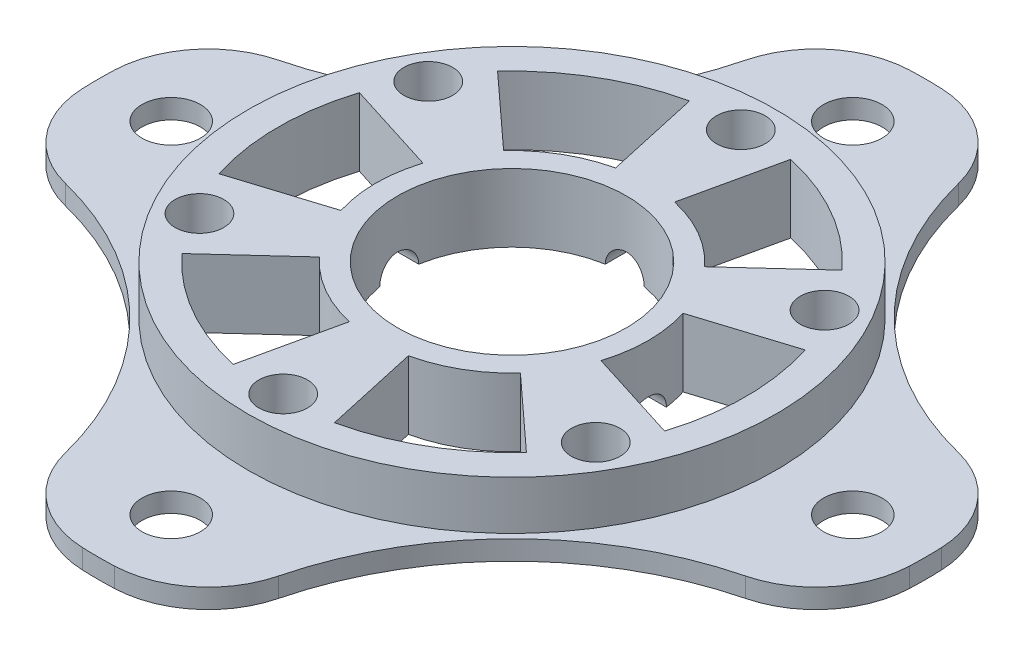
from build123d import *

# Parameters (mm, degrees)
SKETCH1_R           = 27.1
BOSS_EXTRUDE1_DEPTH = 5
SKETCH2_R           = 42.5
BOSS_EXTRUDE2_DEPTH = 2
SKETCH3_R           = 3
CUT_EXTRUDE1_DEPTH  = 2
SKETCH4_R           = 11.75
SKETCH4_R_2         = 2.5
CUT_EXTRUDE2_DEPTH  = 8
CUT_EXTRUDE3_DEPTH  = 8
FILLET1_R           = 10
SKETCH7_R           = 2
CUT_EXTRUDE4_DEPTH  = 15
SKETCH8_R           = 2
CUT_EXTRUDE5_DEPTH  = 25


with BuildPart() as part:
    # Sketch1 → Boss-Extrude1 (new body)
    with BuildSketch(Plane(origin=(0, 0, 0), x_dir=(1, 0, 0), z_dir=(0, 1, 0))):
        Circle(SKETCH1_R)
    extrude(amount=-BOSS_EXTRUDE1_DEPTH)

    # Sketch2 → Boss-Extrude2 (add)
    with BuildSketch(Plane.XZ.offset(5)):
        Circle(SKETCH2_R)
    extrude(amount=BOSS_EXTRUDE2_DEPTH)

    # Sketch3 → Cut-Extrude1 (cut)
    with BuildSketch(Plane(origin=(0, -5, 0), x_dir=(1, 0, 0), z_dir=(0, 1, 0))):
        with BuildLine():
            ThreePointArc((-41.306779105, 10), (-19.624107624, 19.624107624), (-10, 41.306779105))
            ThreePointArc((-10, 41.306779105), (-30.0520382, 30.0520382), (-41.306779105, 10))
        make_face()
        with Locations((0, 35)):
            Circle(SKETCH3_R)
        with BuildLine():
            ThreePointArc((41.306779105, 10), (30.0520382, 30.0520382), (10, 41.306779105))
            ThreePointArc((10, 41.306779105), (19.624107624, 19.624107624), (41.306779105, 10))
        make_face()
        with Locations((35, 0)):
            Circle(SKETCH3_R)
        with Locations((0, -35)):
            Circle(SKETCH3_R)
        with BuildLine():
            ThreePointArc((41.306779105, -10), (19.624107624, -19.624107624), (10, -41.306779105))
            ThreePointArc((10, -41.306779105), (30.0520382, -30.0520382), (41.306779105, -10))
        make_face()
        with BuildLine():
            ThreePointArc((-10, -41.306779105), (-19.624107624, -19.624107624), (-41.306779105, -10))
            ThreePointArc((-41.306779105, -10), (-30.0520382, -30.0520382), (-10, -41.306779105))
        make_face()
        with Locations((-35, 0)):
            Circle(SKETCH3_R)
    extrude(amount=-CUT_EXTRUDE1_DEPTH, mode=Mode.SUBTRACT)

    # Sketch4 → Cut-Extrude2 (cut, through all)
    with BuildSketch(Plane(origin=(0, 0, 0), x_dir=(1, 0, 0), z_dir=(0, 1, 0))):
        Circle(SKETCH4_R)
        with Locations((0, 23.5)):
            Circle(SKETCH4_R_2)
        with Locations((20.351596989, 11.75)):
            Circle(SKETCH4_R_2)
        with Locations((20.351596989, -11.75)):
            Circle(SKETCH4_R_2)
        with Locations((0, -23.5)):
            Circle(SKETCH4_R_2)
        with Locations((-20.351596989, -11.75)):
            Circle(SKETCH4_R_2)
        with Locations((-20.351596989, 11.75)):
            Circle(SKETCH4_R_2)
    extrude(amount=-CUT_EXTRUDE2_DEPTH, mode=Mode.SUBTRACT)

    # Sketch5 → Cut-Extrude3 (cut, through all)
    with BuildSketch(Plane(origin=(0, 0, 0), x_dir=(1, 0, 0), z_dir=(0, 1, 0))):
        with BuildLine():
            Line((-17.694656083, 16.214164983), (-10.321882715, 9.458262907))
            ThreePointArc((-10.321882715, 9.458262907), (-7, 12.124355653), (-3.030154595, 13.6681441))
            Line((-3.030154595, 13.6681441), (-5.194550735, 23.431104171))
            ThreePointArc((-5.194550735, 23.431104171), (-12, 20.784609691), (-17.694656083, 16.214164983))
        make_face()
        with BuildLine():
            Line((17.694656083, 16.214164983), (10.321882715, 9.458262907))
            ThreePointArc((10.321882715, 9.458262907), (7, 12.124355653), (3.030154595, 13.6681441))
            Line((3.030154595, 13.6681441), (5.194550735, 23.431104171))
            ThreePointArc((5.194550735, 23.431104171), (12, 20.784609691), (17.694656083, 16.214164983))
        make_face()
        with BuildLine():
            Line((22.889206818, -7.216939188), (13.35203731, -4.209881193))
            ThreePointArc((13.35203731, -4.209881193), (14, 0), (13.35203731, 4.209881193))
            Line((13.35203731, 4.209881193), (22.889206818, 7.216939188))
            ThreePointArc((22.889206818, 7.216939188), (24, 0), (22.889206818, -7.216939188))
        make_face()
        with BuildLine():
            Line((5.194550735, -23.431104171), (3.030154595, -13.6681441))
            ThreePointArc((3.030154595, -13.6681441), (7, -12.124355653), (10.321882715, -9.458262907))
            Line((10.321882715, -9.458262907), (17.694656083, -16.214164983))
            ThreePointArc((17.694656083, -16.214164983), (12, -20.784609691), (5.194550735, -23.431104171))
        make_face()
        with BuildLine():
            Line((-17.694656083, -16.214164983), (-10.321882715, -9.458262907))
            ThreePointArc((-10.321882715, -9.458262907), (-7, -12.124355653), (-3.030154595, -13.6681441))
            Line((-3.030154595, -13.6681441), (-5.194550735, -23.431104171))
            ThreePointArc((-5.194550735, -23.431104171), (-12, -20.784609691), (-17.694656083, -16.214164983))
        make_face()
        with BuildLine():
            Line((-22.889206818, 7.216939188), (-13.35203731, 4.209881193))
            ThreePointArc((-13.35203731, 4.209881193), (-14, 0), (-13.35203731, -4.209881193))
            Line((-13.35203731, -4.209881193), (-22.889206818, -7.216939188))
            ThreePointArc((-22.889206818, -7.216939188), (-24, 0), (-22.889206818, 7.216939188))
        make_face()
    extrude(amount=-CUT_EXTRUDE3_DEPTH, mode=Mode.SUBTRACT)

    # Fillet1
    fillet1_edges = [part.edges().sort_by_distance(p)[0] for p in [
        (41.306779105, -6, -10),
        (10, -6, -41.306779105),
        (10, -6, 41.306779105),
        (41.306779105, -6, 10),
        (-41.306779105, -6, 10),
        (-10, -6, 41.306779105),
        (-10, -6, -41.306779105),
        (-41.306779105, -6, -10),
    ]]
    fillet(fillet1_edges, radius=FILLET1_R)

    # Sketch7 → Cut-Extrude4 (cut, symmetric)
    with BuildSketch(Plane(origin=(0, 0, 0), x_dir=(0, 0, -1), z_dir=(1, 0, 0))):
        with Locations((0, -7)):
            Circle(SKETCH7_R)
    extrude(amount=CUT_EXTRUDE4_DEPTH, both=True, mode=Mode.SUBTRACT)

    # Sketch8 → Cut-Extrude5 (cut, symmetric)
    with BuildSketch(Plane.XY):
        with Locations((0, -7)):
            Circle(SKETCH8_R)
    extrude(amount=CUT_EXTRUDE5_DEPTH, both=True, mode=Mode.SUBTRACT)


solid = part.part
